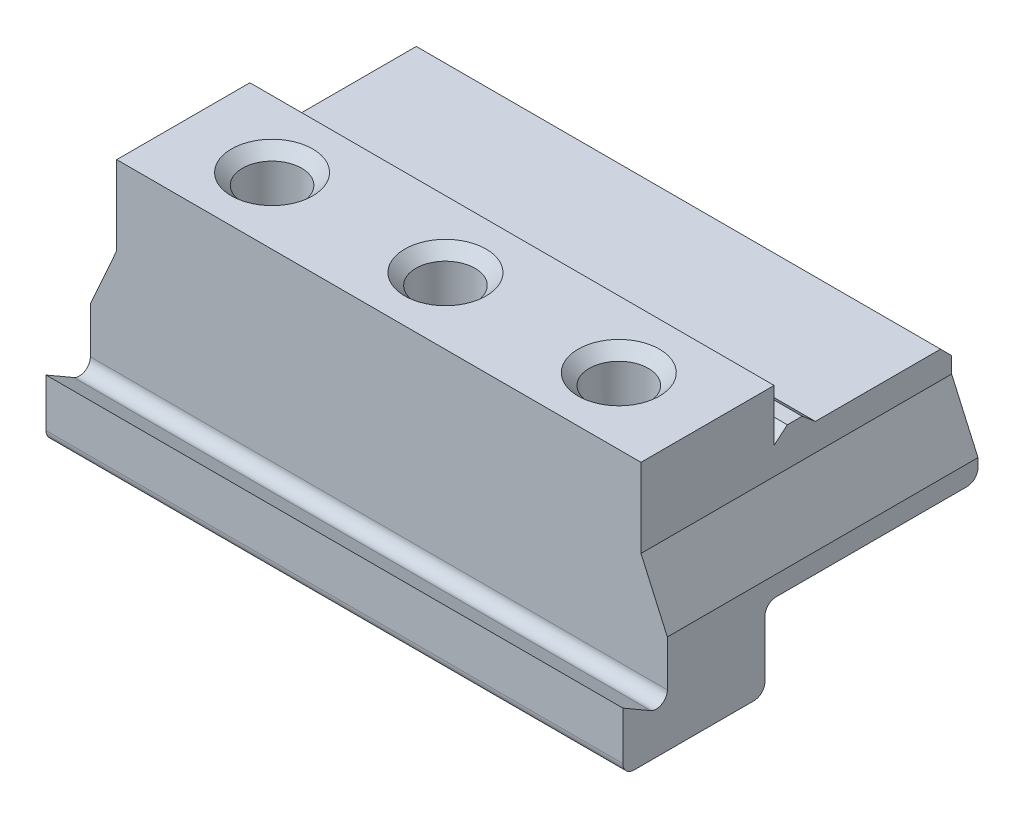
from build123d import *

# Parameters (mm, degrees)
SKETCH1_W               = 78
SKETCH1_H               = 48
BOSS_EXTRUDE1_DEPTH     = 32
CUT_EXTRUDE1_DEPTH      = 1
CUT_EXTRUDE1_DEPTH_BACK = 49
SKETCH3_OUTSIDE_W       = 69.404
SKETCH3_OUTSIDE_H       = 53.404
CUT_EXTRUDE3_DEPTH      = 1
CUT_EXTRUDE3_DEPTH_BACK = 79
FILLET1_R               = 1.5
SKETCH4_R               = 4
CUT_EXTRUDE4_DEPTH      = 1
CUT_EXTRUDE4_DEPTH_BACK = 10
CHAMFER1_SIZE           = 1.5


with BuildPart() as part:
    # Sketch1 → Boss-Extrude1 (new body)
    with BuildSketch(Plane(origin=(0, 0, 0), x_dir=(1, 0, 0), z_dir=(0, 1, 0))):
        Rectangle(SKETCH1_W, SKETCH1_H)
    extrude(amount=BOSS_EXTRUDE1_DEPTH)

    # Sketch2 → Cut-Extrude1 (cut, two sides)
    with BuildSketch(Plane.XY.offset(24)) as cut_extrude1_sk:
        Polygon((-39, 13.33), (-35.438170518, 21.33), (-35.438170518, 32), (-39, 32), align=None)
        Polygon((35.438170518, 21.33), (35.438170518, 32), (39, 32), (39, 13.33), align=None)
    extrude(amount=CUT_EXTRUDE1_DEPTH, mode=Mode.SUBTRACT)
    extrude(cut_extrude1_sk.sketch, amount=-CUT_EXTRUDE1_DEPTH_BACK, mode=Mode.SUBTRACT)

    # Sketch3 outside → Cut-Extrude3 (cut, two sides)
    with BuildSketch(Plane(origin=(39, 0, 0), x_dir=(0, 0, -1), z_dir=(1, 0, 0))) as cut_extrude3_sk:
        with Locations((0, 16)):
            Rectangle(SKETCH3_OUTSIDE_W, SKETCH3_OUTSIDE_H)
        Polygon((-24, 8), (-18, 4.535898385), (-18, 32), (0, 32), (0, 25), (1.787630389, 26.5), (3.787630389, 26.5), (5.575260778, 25), (24, 25), (24, 10.67), (-4.8, 10.67), (-4.8, 0), (-24, 0), align=None, mode=Mode.SUBTRACT)
    extrude(amount=CUT_EXTRUDE3_DEPTH, mode=Mode.SUBTRACT)
    extrude(cut_extrude3_sk.sketch, amount=-CUT_EXTRUDE3_DEPTH_BACK, mode=Mode.SUBTRACT)

    # Fillet1
    fillet1_edges = [part.edges().sort_by_distance(p)[0] for p in [
        (0, 0, 24),
        (0, 10.67, 4.8),
        (0, 4.535898385, 18),
        (0, 0, 4.8),
        (0, 10.67, -24),
    ]]
    fillet(fillet1_edges, radius=FILLET1_R)

    # Sketch4 → Cut-Extrude4 (cut, two sides)
    with BuildSketch(Plane(origin=(0, 32, 0), x_dir=(1, 0, 0), z_dir=(0, 1, 0))) as cut_extrude4_sk:
        with Locations((0, -9)):
            Circle(SKETCH4_R)
        with Locations((23.438170518, -9)):
            Circle(SKETCH4_R)
        with Locations((-23.438170518, -9)):
            Circle(SKETCH4_R)
    extrude(amount=CUT_EXTRUDE4_DEPTH, mode=Mode.SUBTRACT)
    extrude(cut_extrude4_sk.sketch, amount=-CUT_EXTRUDE4_DEPTH_BACK, mode=Mode.SUBTRACT)

    # Chamfer1
    chamfer1_edges = [part.edges().sort_by_distance(p)[0] for p in [
        (-27.438170518, 32, 9),
        (19.438170518, 32, 9),
        (-4, 32, 9),
        (0, 25, -24),
    ]]
    chamfer(chamfer1_edges, length=CHAMFER1_SIZE)


solid = part.part
